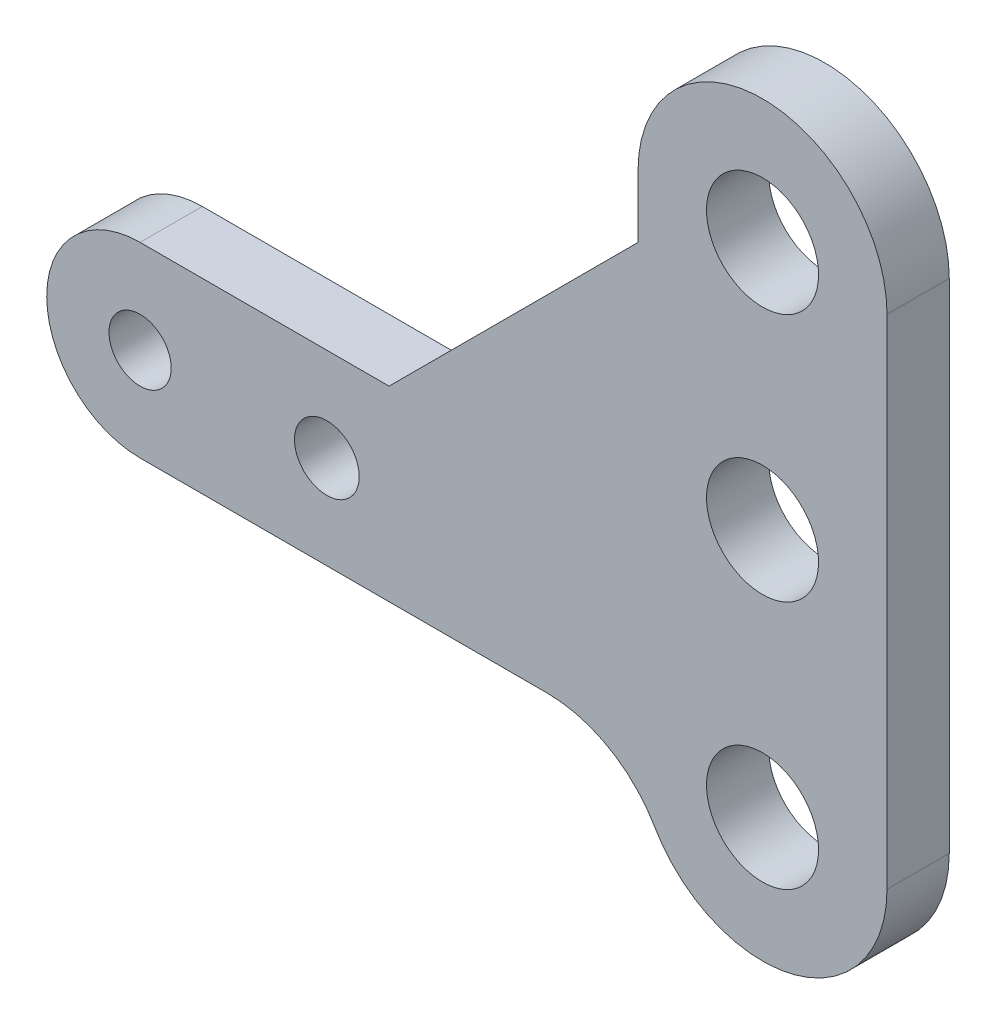
from build123d import *

# Parameters (mm, degrees)
SKETCH_1_R          = 2.6
SKETCH_1_R_2        = 2.5
EXTRUDE_1_DEPTH     = 5
SKETCH_2_R          = 4.5
CUT_EXTRUDE_1_DEPTH = 10
CHAMFER_1_SIZE      = 20
FILLET_1_R          = 10


with BuildPart() as part:
    # 草图1 → 凸台-拉伸1 (new body)
    with BuildSketch(Plane.XY):
        with BuildLine():
            Line((-15, 7.5), (0, 7.5))
            Line((0, 7.5), (15, 7.5))
            Line((15, 7.5), (25, 7.5))
            Line((25, 7.5), (25, 32.5))
            ThreePointArc((25, 32.5), (35, 42.5), (45, 32.5))
            Line((45, 32.5), (45, -7.5))
            ThreePointArc((45, -7.5), (35, -17.5), (25, -7.5))
            Line((25, -7.5), (15, -7.5))
            Line((15, -7.5), (0, -7.5))
            Line((0, -7.5), (-15, -7.5))
            ThreePointArc((-15, -7.5), (-22.5, 0), (-15, 7.5))
        make_face()
        Circle(SKETCH_1_R, mode=Mode.SUBTRACT)
        with Locations((-15, 0)):
            Circle(SKETCH_1_R_2, mode=Mode.SUBTRACT)
    extrude(amount=-EXTRUDE_1_DEPTH)

    # 草图2 → 切除-拉伸1 (cut)
    with BuildSketch(Plane.XY):
        with Locations((35, -7.5)):
            Circle(SKETCH_2_R)
        with Locations((35, 32.5)):
            Circle(SKETCH_2_R)
        with Locations((35, 12.5)):
            Circle(SKETCH_2_R)
    extrude(amount=-CUT_EXTRUDE_1_DEPTH, mode=Mode.SUBTRACT)

    # 倒角1
    chamfer_1_edges = [part.edges().sort_by_distance(p)[0] for p in [
        (25, 7.5, -2.5),
    ]]
    chamfer(chamfer_1_edges, length=CHAMFER_1_SIZE)

    # 圆角1
    fillet_1_edges = [part.edges().sort_by_distance(p)[0] for p in [
        (25, -7.5, -2.5),
    ]]
    fillet(fillet_1_edges, radius=FILLET_1_R)


solid = part.part
